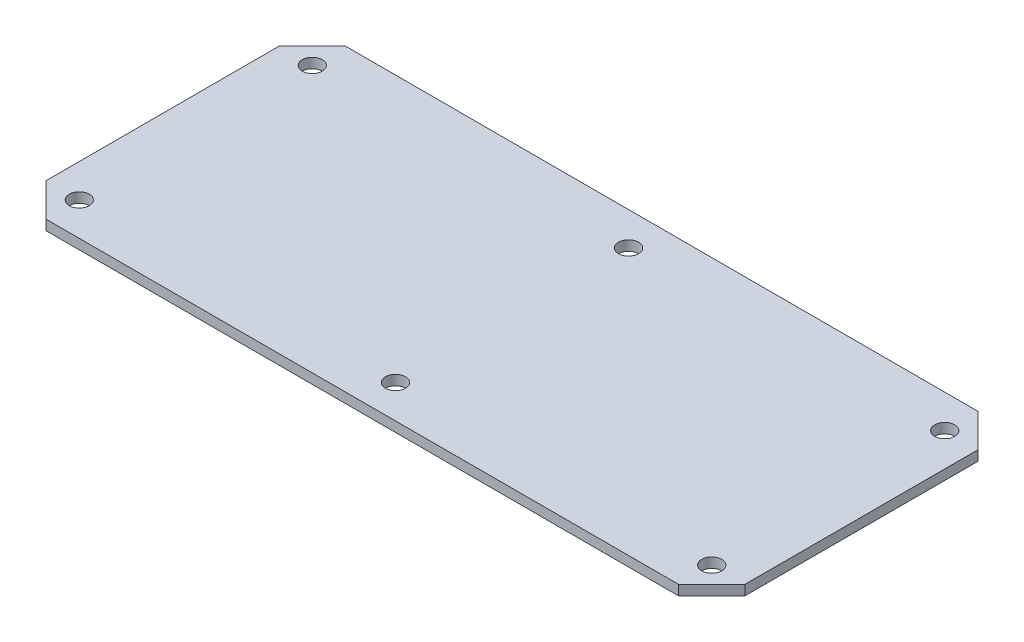
from build123d import *

# Parameters (mm, degrees)
ESQUISSE1_W             = 210
ESQUISSE1_H             = 90
BOSS_EXTRU_1_DEPTH      = 3
ESQUISSE2_R             = 3
ENL_V_MAT_EXTRU_1_DEPTH = 3
CHAMFER1_SIZE           = 10


with BuildPart() as part:
    # Esquisse1 → Boss.-Extru.1 (new body)
    with BuildSketch(Plane(origin=(0, 0, 0), x_dir=(1, 0, 0), z_dir=(0, 1, 0))):
        with Locations((105, 45)):
            Rectangle(ESQUISSE1_W, ESQUISSE1_H)
    extrude(amount=BOSS_EXTRU_1_DEPTH)

    # Esquisse2 → Enlèv. mat.-Extru.1 (cut)
    with BuildSketch(Plane(origin=(0, 3, 0), x_dir=(1, 0, 0), z_dir=(0, 1, 0))):
        with Locations((10, 80)):
            Circle(ESQUISSE2_R)
        with Locations((105, 80)):
            Circle(ESQUISSE2_R)
        with Locations((200, 80)):
            Circle(ESQUISSE2_R)
        with Locations((200, 10)):
            Circle(ESQUISSE2_R)
        with Locations((105, 10)):
            Circle(ESQUISSE2_R)
        with Locations((10, 10)):
            Circle(ESQUISSE2_R)
    extrude(amount=-ENL_V_MAT_EXTRU_1_DEPTH, mode=Mode.SUBTRACT)

    # Chamfer1
    chamfer1_edges = [part.edges().sort_by_distance(p)[0] for p in [
        (210, 1.5, 0),
        (0, 1.5, 0),
        (0, 1.5, -90),
        (210, 1.5, -90),
    ]]
    chamfer(chamfer1_edges, length=CHAMFER1_SIZE)


solid = part.part
